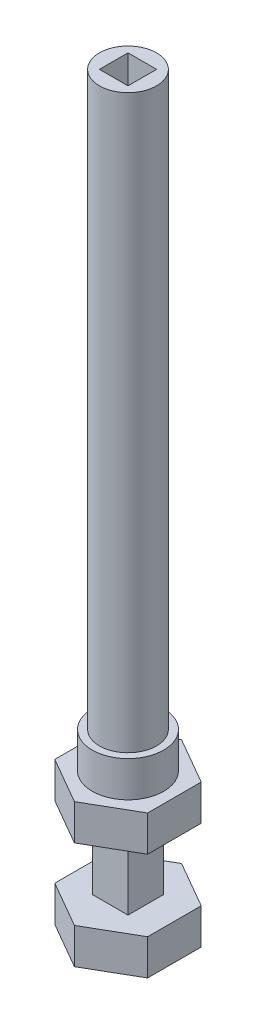
from build123d import *

# Parameters (mm, degrees)
SKETCH1_W           = 5
SKETCH1_H           = 5
BOSS_EXTRUDE1_DEPTH = 10
BOSS_EXTRUDE2_DEPTH = 5
BOSS_EXTRUDE3_DEPTH = 5
SKETCH4_R           = 5
BOSS_EXTRUDE4_DEPTH = 5
SKETCH5_R           = 4
BOSS_EXTRUDE5_DEPTH = 80
SKETCH6_W           = 4
SKETCH6_H           = 4
CUT_EXTRUDE1_DEPTH  = 4


with BuildPart() as part:
    # Sketch1 → Boss-Extrude1 (new body)
    with BuildSketch(Plane(origin=(0, 0, 0), x_dir=(1, 0, 0), z_dir=(0, 1, 0))):
        Rectangle(SKETCH1_W, SKETCH1_H)
    extrude(amount=BOSS_EXTRUDE1_DEPTH)

    # Sketch2 → Boss-Extrude2 (add)
    with BuildSketch(Plane.XZ):
        Polygon((0, 7.5), (-6.495190528, 3.75), (-6.495190528, -3.75), (0, -7.5), (6.495190528, -3.75), (6.495190528, 3.75), align=None)
    extrude(amount=BOSS_EXTRUDE2_DEPTH)

    # Sketch3 → Boss-Extrude3 (add)
    with BuildSketch(Plane(origin=(0, 10, 0), x_dir=(1, 0, 0), z_dir=(0, 1, 0))):
        Polygon((0, -7.5), (6.495190528, -3.75), (6.495190528, 3.75), (0, 7.5), (-6.495190528, 3.75), (-6.495190528, -3.75), align=None)
    extrude(amount=BOSS_EXTRUDE3_DEPTH)

    # Sketch4 → Boss-Extrude4 (add)
    with BuildSketch(Plane(origin=(0, 15, 0), x_dir=(1, 0, 0), z_dir=(0, 1, 0))):
        Circle(SKETCH4_R)
    extrude(amount=BOSS_EXTRUDE4_DEPTH)

    # Sketch5 → Boss-Extrude5 (add)
    with BuildSketch(Plane(origin=(0, 20, 0), x_dir=(1, 0, 0), z_dir=(0, 1, 0))):
        Circle(SKETCH5_R)
    extrude(amount=BOSS_EXTRUDE5_DEPTH)

    # Sketch6 → Cut-Extrude1 (cut)
    with BuildSketch(Plane(origin=(0, 100, 0), x_dir=(1, 0, 0), z_dir=(0, 1, 0))):
        Rectangle(SKETCH6_W, SKETCH6_H)
    extrude(amount=-CUT_EXTRUDE1_DEPTH, mode=Mode.SUBTRACT)


solid = part.part
